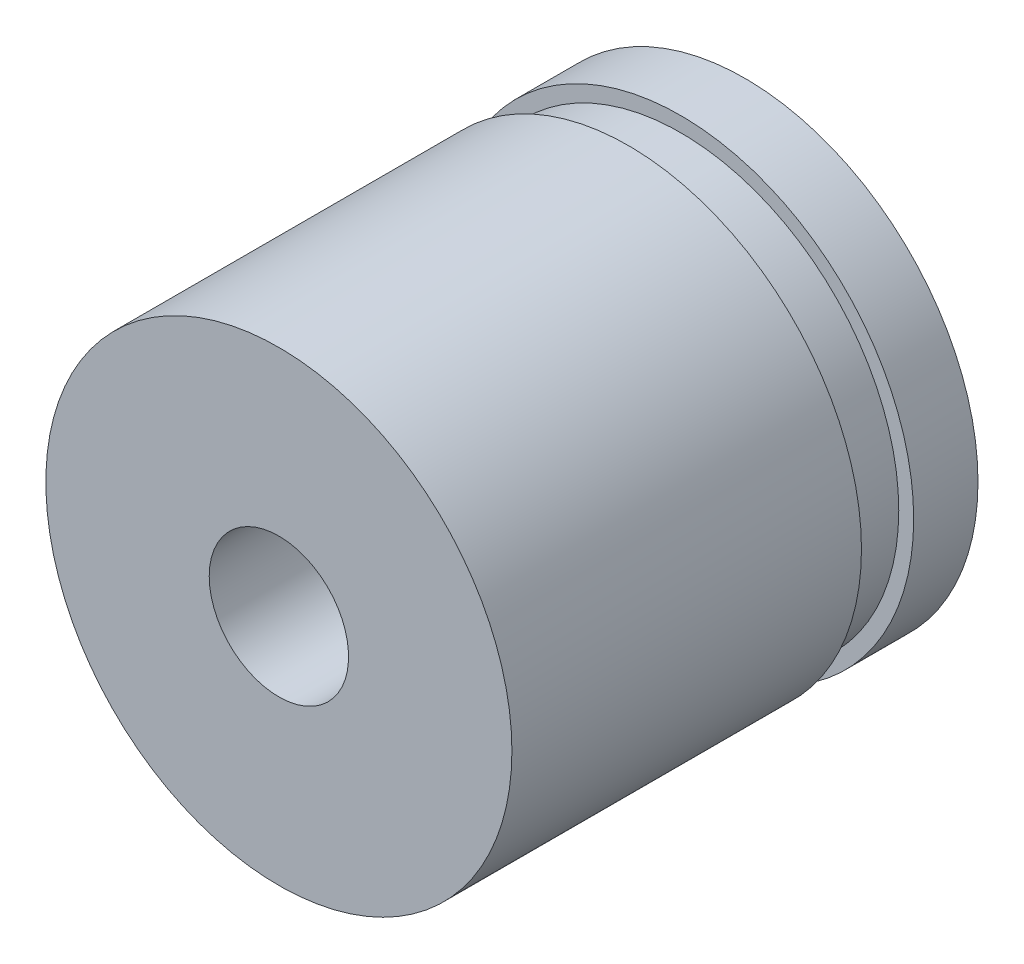
from build123d import *

# Parameters (mm, degrees)
SKETCH4_R                = 6.35
BOSS_EXTRUDE1_DEPTH      = 6.35
BOSS_EXTRUDE1_DEPTH_BACK = 6.35
SKETCH5_R                = 6.35
SKETCH5_R_2              = 5.9436
CUT_EXTRUDE1_DEPTH       = 1.4224
SKETCH7_W                = 1.89865
SKETCH7_H                = 6.35


with BuildPart() as part:
    # Sketch4 → Boss-Extrude1 (new body, two sides)
    with BuildSketch(Plane.XY.offset(39.04234)) as boss_extrude1_sk:
        with Locations((-94.293901082, 0)):
            Circle(SKETCH4_R)
    extrude(amount=BOSS_EXTRUDE1_DEPTH)
    extrude(boss_extrude1_sk.sketch, amount=-BOSS_EXTRUDE1_DEPTH_BACK)

    # Sketch5 → Cut-Extrude1 (cut)
    with BuildSketch(Plane.XY.offset(34.44494)):
        with Locations((-94.293901082, 0)):
            Circle(SKETCH5_R)
        with Locations((-94.293901082, 0)):
            Circle(SKETCH5_R_2, mode=Mode.SUBTRACT)
    extrude(amount=CUT_EXTRUDE1_DEPTH, mode=Mode.SUBTRACT)

    # Sketch7 → Tap Drill for _10-24 Tap1 (revolve, cut)
    with BuildSketch(Plane(origin=(-94.293901082, 0, 39.04234), x_dir=(0, 1, 0), z_dir=(1, 0, 0))):
        with Locations((0.949325, 3.175)):
            Rectangle(SKETCH7_W, SKETCH7_H)
    revolve(axis=Axis((-94.293901082, 0, 32.69234), (0, 0, 1)), mode=Mode.SUBTRACT)


solid = part.part
